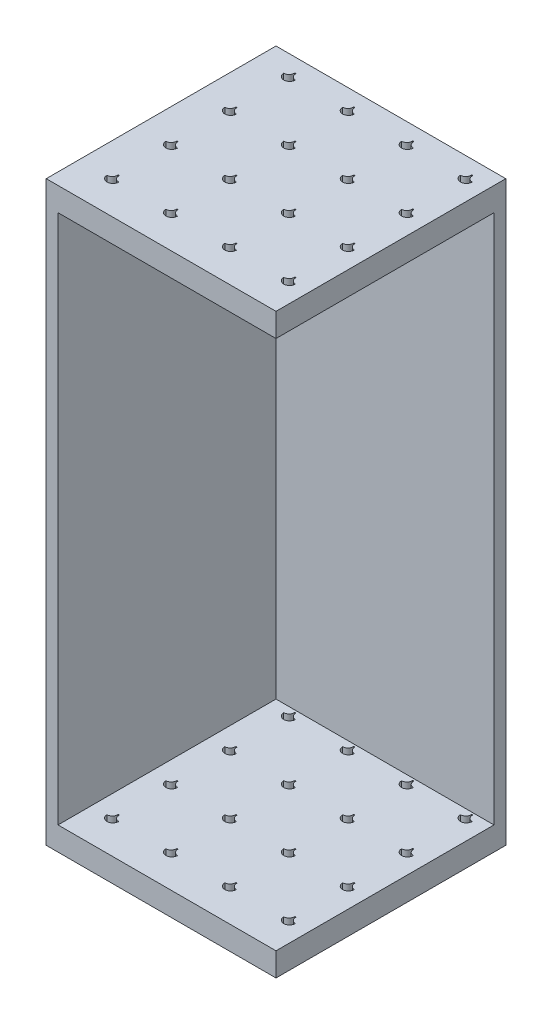
from build123d import *

# Parameters (mm, degrees)
SKETCH1_W           = 19.5
SKETCH1_H           = 19.5
BOSS_EXTRUDE1_DEPTH = 2
BOSS_EXTRUDE2_DEPTH = 45
SKETCH5_W           = 19.5
SKETCH5_H           = 19.5
BOSS_EXTRUDE5_DEPTH = 2
CUT_EXTRUDE1_DEPTH  = 50


with BuildPart() as part:
    # Sketch1 → Boss-Extrude1 (new body)
    with BuildSketch(Plane(origin=(0, 0, 0), x_dir=(1, 0, 0), z_dir=(0, 1, 0))):
        Rectangle(SKETCH1_W, SKETCH1_H)
    extrude(amount=BOSS_EXTRUDE1_DEPTH)

    # Sketch2 → Boss-Extrude2 (add)
    with BuildSketch(Plane(origin=(0, 2, 0), x_dir=(1, 0, 0), z_dir=(0, 1, 0))):
        Polygon((9.75, 8.75), (-8.75, 8.75), (-8.75, -9.75), (-9.75, -9.75), (-9.75, 9.75), (9.75, 9.75), align=None)
    extrude(amount=BOSS_EXTRUDE2_DEPTH)

    # Sketch5 → Boss-Extrude5 (add)
    with BuildSketch(Plane(origin=(0, 47, 0), x_dir=(1, 0, 0), z_dir=(0, 1, 0))):
        Rectangle(SKETCH5_W, SKETCH5_H)
    extrude(amount=BOSS_EXTRUDE5_DEPTH)

    # Sketch3 → Cut-Extrude1 (cut, through all)
    with BuildSketch(Plane.XZ):
        with BuildLine():
            Line((-6.971572875, 6.471572875), (-6.971572875, 6.424079157))
            ThreePointArc((-6.971572875, 6.424079157), (-6.921572875, 6.421572875), (-6.871572875, 6.424079157))
            Line((-6.871572875, 6.424079157), (-6.871572875, 6.471572875))
            ThreePointArc((-6.871572875, 6.471572875), (-6.739770927, 6.789770927), (-6.421572875, 6.921572875))
            ThreePointArc((-6.421572875, 6.921572875), (-6.921572875, 7.421572875), (-7.421572875, 6.921572875))
            ThreePointArc((-7.421572875, 6.921572875), (-7.103374824, 6.789770927), (-6.971572875, 6.471572875))
        make_face()
        with BuildLine():
            Line((-1.871572875, 6.471572875), (-1.871572875, 6.424079157))
            ThreePointArc((-1.871572875, 6.424079157), (-1.921572875, 6.421572875), (-1.971572875, 6.424079157))
            Line((-1.971572875, 6.424079157), (-1.971572875, 6.471572875))
            ThreePointArc((-1.971572875, 6.471572875), (-2.103374824, 6.789770927), (-2.421572875, 6.921572875))
            ThreePointArc((-2.421572875, 6.921572875), (-1.921572875, 7.421572875), (-1.421572875, 6.921572875))
            ThreePointArc((-1.421572875, 6.921572875), (-1.739770927, 6.789770927), (-1.871572875, 6.471572875))
        make_face()
        with BuildLine():
            Line((3.128427125, 6.471572875), (3.128427125, 6.424079157))
            ThreePointArc((3.128427125, 6.424079157), (3.078427125, 6.421572875), (3.028427125, 6.424079157))
            Line((3.028427125, 6.424079157), (3.028427125, 6.471572875))
            ThreePointArc((3.028427125, 6.471572875), (2.896625176, 6.789770927), (2.578427125, 6.921572875))
            ThreePointArc((2.578427125, 6.921572875), (3.078427125, 7.421572875), (3.578427125, 6.921572875))
            ThreePointArc((3.578427125, 6.921572875), (3.260229073, 6.789770927), (3.128427125, 6.471572875))
        make_face()
        with BuildLine():
            Line((8.128427125, 6.471572875), (8.128427125, 6.424079157))
            ThreePointArc((8.128427125, 6.424079157), (8.078427125, 6.421572875), (8.028427125, 6.424079157))
            Line((8.028427125, 6.424079157), (8.028427125, 6.471572875))
            ThreePointArc((8.028427125, 6.471572875), (7.896625176, 6.789770927), (7.578427125, 6.921572875))
            ThreePointArc((7.578427125, 6.921572875), (8.078427125, 7.421572875), (8.578427125, 6.921572875))
            ThreePointArc((8.578427125, 6.921572875), (8.260229073, 6.789770927), (8.128427125, 6.471572875))
        make_face()
        with BuildLine():
            Line((-1.871572875, 1.471572875), (-1.871572875, 1.424079157))
            ThreePointArc((-1.871572875, 1.424079157), (-1.921572875, 1.421572875), (-1.971572875, 1.424079157))
            Line((-1.971572875, 1.424079157), (-1.971572875, 1.471572875))
            ThreePointArc((-1.971572875, 1.471572875), (-2.103374824, 1.789770927), (-2.421572875, 1.921572875))
            ThreePointArc((-2.421572875, 1.921572875), (-1.921572875, 2.421572875), (-1.421572875, 1.921572875))
            ThreePointArc((-1.421572875, 1.921572875), (-1.739770927, 1.789770927), (-1.871572875, 1.471572875))
        make_face()
        with BuildLine():
            Line((3.128427125, 1.471572875), (3.128427125, 1.424079157))
            ThreePointArc((3.128427125, 1.424079157), (3.078427125, 1.421572875), (3.028427125, 1.424079157))
            Line((3.028427125, 1.424079157), (3.028427125, 1.471572875))
            ThreePointArc((3.028427125, 1.471572875), (2.896625176, 1.789770927), (2.578427125, 1.921572875))
            ThreePointArc((2.578427125, 1.921572875), (3.078427125, 2.421572875), (3.578427125, 1.921572875))
            ThreePointArc((3.578427125, 1.921572875), (3.260229073, 1.789770927), (3.128427125, 1.471572875))
        make_face()
        with BuildLine():
            Line((8.128427125, 1.471572875), (8.128427125, 1.424079157))
            ThreePointArc((8.128427125, 1.424079157), (8.078427125, 1.421572875), (8.028427125, 1.424079157))
            Line((8.028427125, 1.424079157), (8.028427125, 1.471572875))
            ThreePointArc((8.028427125, 1.471572875), (7.896625176, 1.789770927), (7.578427125, 1.921572875))
            ThreePointArc((7.578427125, 1.921572875), (8.078427125, 2.421572875), (8.578427125, 1.921572875))
            ThreePointArc((8.578427125, 1.921572875), (8.260229073, 1.789770927), (8.128427125, 1.471572875))
        make_face()
        with BuildLine():
            Line((-1.871572875, -3.528427125), (-1.871572875, -3.575920843))
            ThreePointArc((-1.871572875, -3.575920843), (-1.921572875, -3.578427125), (-1.971572875, -3.575920843))
            Line((-1.971572875, -3.575920843), (-1.971572875, -3.528427125))
            ThreePointArc((-1.971572875, -3.528427125), (-2.103374824, -3.210229073), (-2.421572875, -3.078427125))
            ThreePointArc((-2.421572875, -3.078427125), (-1.921572875, -2.578427125), (-1.421572875, -3.078427125))
            ThreePointArc((-1.421572875, -3.078427125), (-1.739770927, -3.210229073), (-1.871572875, -3.528427125))
        make_face()
        with BuildLine():
            Line((3.128427125, -3.528427125), (3.128427125, -3.575920843))
            ThreePointArc((3.128427125, -3.575920843), (3.078427125, -3.578427125), (3.028427125, -3.575920843))
            Line((3.028427125, -3.575920843), (3.028427125, -3.528427125))
            ThreePointArc((3.028427125, -3.528427125), (2.896625176, -3.210229073), (2.578427125, -3.078427125))
            ThreePointArc((2.578427125, -3.078427125), (3.078427125, -2.578427125), (3.578427125, -3.078427125))
            ThreePointArc((3.578427125, -3.078427125), (3.260229073, -3.210229073), (3.128427125, -3.528427125))
        make_face()
        with BuildLine():
            Line((8.128427125, -3.528427125), (8.128427125, -3.575920843))
            ThreePointArc((8.128427125, -3.575920843), (8.078427125, -3.578427125), (8.028427125, -3.575920843))
            Line((8.028427125, -3.575920843), (8.028427125, -3.528427125))
            ThreePointArc((8.028427125, -3.528427125), (7.896625176, -3.210229073), (7.578427125, -3.078427125))
            ThreePointArc((7.578427125, -3.078427125), (8.078427125, -2.578427125), (8.578427125, -3.078427125))
            ThreePointArc((8.578427125, -3.078427125), (8.260229073, -3.210229073), (8.128427125, -3.528427125))
        make_face()
        with BuildLine():
            Line((-1.871572875, -8.528427125), (-1.871572875, -8.575920843))
            ThreePointArc((-1.871572875, -8.575920843), (-1.921572875, -8.578427125), (-1.971572875, -8.575920843))
            Line((-1.971572875, -8.575920843), (-1.971572875, -8.528427125))
            ThreePointArc((-1.971572875, -8.528427125), (-2.103374824, -8.210229073), (-2.421572875, -8.078427125))
            ThreePointArc((-2.421572875, -8.078427125), (-1.921572875, -7.578427125), (-1.421572875, -8.078427125))
            ThreePointArc((-1.421572875, -8.078427125), (-1.739770927, -8.210229073), (-1.871572875, -8.528427125))
        make_face()
        with BuildLine():
            Line((3.128427125, -8.528427125), (3.128427125, -8.575920843))
            ThreePointArc((3.128427125, -8.575920843), (3.078427125, -8.578427125), (3.028427125, -8.575920843))
            Line((3.028427125, -8.575920843), (3.028427125, -8.528427125))
            ThreePointArc((3.028427125, -8.528427125), (2.896625176, -8.210229073), (2.578427125, -8.078427125))
            ThreePointArc((2.578427125, -8.078427125), (3.078427125, -7.578427125), (3.578427125, -8.078427125))
            ThreePointArc((3.578427125, -8.078427125), (3.260229073, -8.210229073), (3.128427125, -8.528427125))
        make_face()
        with BuildLine():
            Line((8.128427125, -8.528427125), (8.128427125, -8.575920843))
            ThreePointArc((8.128427125, -8.575920843), (8.078427125, -8.578427125), (8.028427125, -8.575920843))
            Line((8.028427125, -8.575920843), (8.028427125, -8.528427125))
            ThreePointArc((8.028427125, -8.528427125), (7.896625176, -8.210229073), (7.578427125, -8.078427125))
            ThreePointArc((7.578427125, -8.078427125), (8.078427125, -7.578427125), (8.578427125, -8.078427125))
            ThreePointArc((8.578427125, -8.078427125), (8.260229073, -8.210229073), (8.128427125, -8.528427125))
        make_face()
        with BuildLine():
            Line((-6.871572875, 1.471572875), (-6.871572875, 1.424079157))
            ThreePointArc((-6.871572875, 1.424079157), (-6.921572875, 1.421572875), (-6.971572875, 1.424079157))
            Line((-6.971572875, 1.424079157), (-6.971572875, 1.471572875))
            ThreePointArc((-6.971572875, 1.471572875), (-7.103374824, 1.789770927), (-7.421572875, 1.921572875))
            ThreePointArc((-7.421572875, 1.921572875), (-6.921572875, 2.421572875), (-6.421572875, 1.921572875))
            ThreePointArc((-6.421572875, 1.921572875), (-6.739770927, 1.789770927), (-6.871572875, 1.471572875))
        make_face()
        with BuildLine():
            Line((-6.871572875, -3.528427125), (-6.871572875, -3.575920843))
            ThreePointArc((-6.871572875, -3.575920843), (-6.921572875, -3.578427125), (-6.971572875, -3.575920843))
            Line((-6.971572875, -3.575920843), (-6.971572875, -3.528427125))
            ThreePointArc((-6.971572875, -3.528427125), (-7.103374824, -3.210229073), (-7.421572875, -3.078427125))
            ThreePointArc((-7.421572875, -3.078427125), (-6.921572875, -2.578427125), (-6.421572875, -3.078427125))
            ThreePointArc((-6.421572875, -3.078427125), (-6.739770927, -3.210229073), (-6.871572875, -3.528427125))
        make_face()
        with BuildLine():
            Line((-6.871572875, -8.528427125), (-6.871572875, -8.575920843))
            ThreePointArc((-6.871572875, -8.575920843), (-6.921572875, -8.578427125), (-6.971572875, -8.575920843))
            Line((-6.971572875, -8.575920843), (-6.971572875, -8.528427125))
            ThreePointArc((-6.971572875, -8.528427125), (-7.103374824, -8.210229073), (-7.421572875, -8.078427125))
            ThreePointArc((-7.421572875, -8.078427125), (-6.921572875, -7.578427125), (-6.421572875, -8.078427125))
            ThreePointArc((-6.421572875, -8.078427125), (-6.739770927, -8.210229073), (-6.871572875, -8.528427125))
        make_face()
    extrude(amount=-CUT_EXTRUDE1_DEPTH, mode=Mode.SUBTRACT)


solid = part.part
